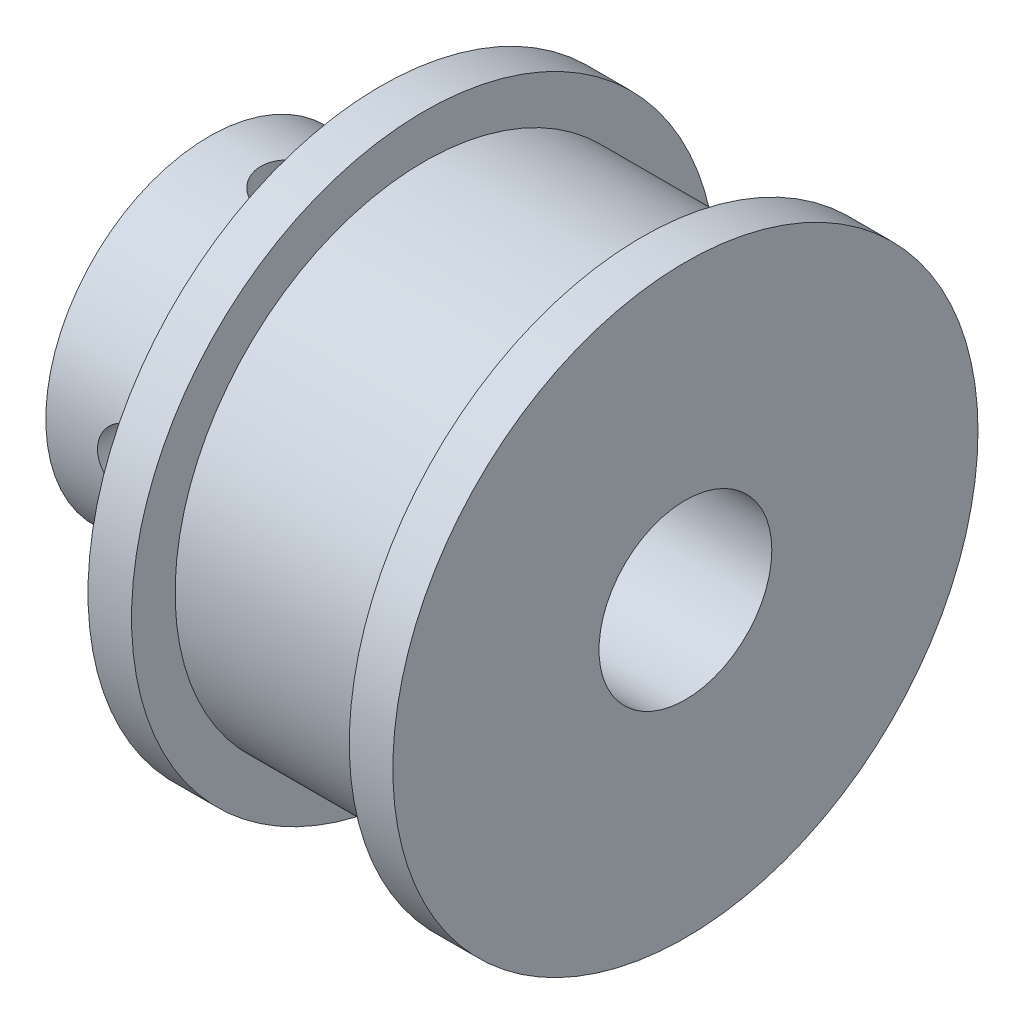
from build123d import *

# Parameters (mm, degrees)
SKETCH2_W = 1.25
SKETCH2_H = 10.75
SKETCH4_W = 1.25
SKETCH4_H = 10.75


with BuildPart() as part:
    # Sketch1 → Revolve1 (revolve)
    with BuildSketch(Plane.XY):
        Polygon((0, 3.175), (0, 6), (6.3, 6), (6.3, 10.75), (7.9, 10.75), (7.9, 9.15), (15.9, 9.15), (15.9, 10.75), (17.5, 10.75), (17.5, 3.175), align=None)
    revolve(axis=Axis((0, 0, 0), (-1, 0, 0)))

    # Sketch2 → M3x0.5 Tapped Hole1 (revolve, cut)
    with BuildSketch(Plane(origin=(3.15, 0, 0), x_dir=(0, 0, -1), z_dir=(1, 0, 0))):
        with Locations((0.625, 5.375)):
            Rectangle(SKETCH2_W, SKETCH2_H)
    revolve(axis=Axis((3.15, -6.35, 0), (0, 1, 0)), mode=Mode.SUBTRACT)

    # Sketch4 → M3x0.5 Tapped Hole2 (revolve, cut)
    with BuildSketch(Plane.YZ.offset(3.15)):
        with Locations((0.625, 5.375)):
            Rectangle(SKETCH4_W, SKETCH4_H)
    revolve(axis=Axis((3.15, 0, -6.35), (0, 0, 1)), mode=Mode.SUBTRACT)


solid = part.part
